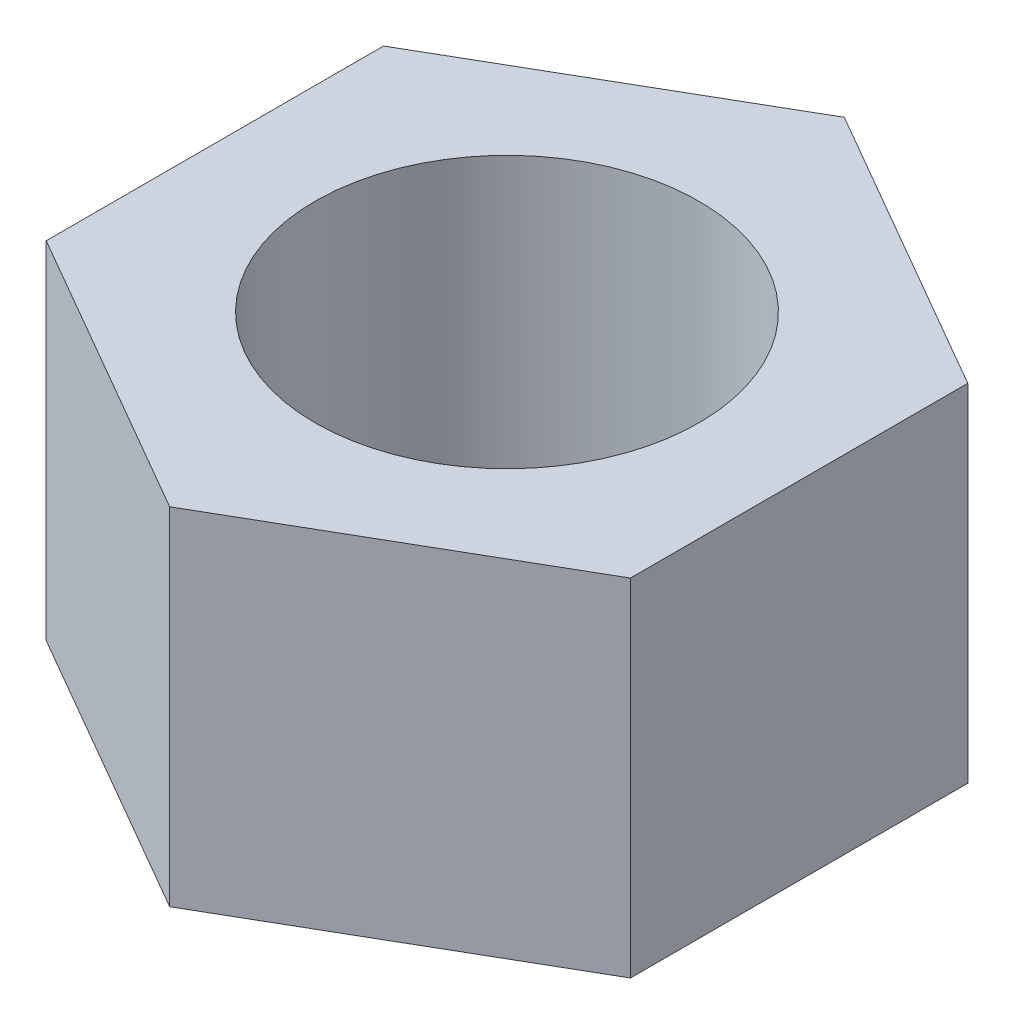
from build123d import *

# Parameters (mm, degrees)
BOSS_EXTRUDE1_DEPTH = 8.3
SKETCH2_R           = 4.6
CUT_EXTRUDE1_DEPTH  = 9.3


with BuildPart() as part:
    # Sketch1 → Boss-Extrude1 (new body)
    with BuildSketch(Plane(origin=(0, 0, 0), x_dir=(1, 0, 0), z_dir=(0, 1, 0))):
        Polygon((0, 8.082903769), (-7, 4.041451884), (-7, -4.041451884), (0, -8.082903769), (7, -4.041451884), (7, 4.041451884), align=None)
    extrude(amount=BOSS_EXTRUDE1_DEPTH)

    # Sketch2 → Cut-Extrude1 (cut, through all)
    with BuildSketch(Plane(origin=(0, 8.3, 0), x_dir=(1, 0, 0), z_dir=(0, 1, 0))):
        Circle(SKETCH2_R)
    extrude(amount=-CUT_EXTRUDE1_DEPTH, mode=Mode.SUBTRACT)


solid = part.part
